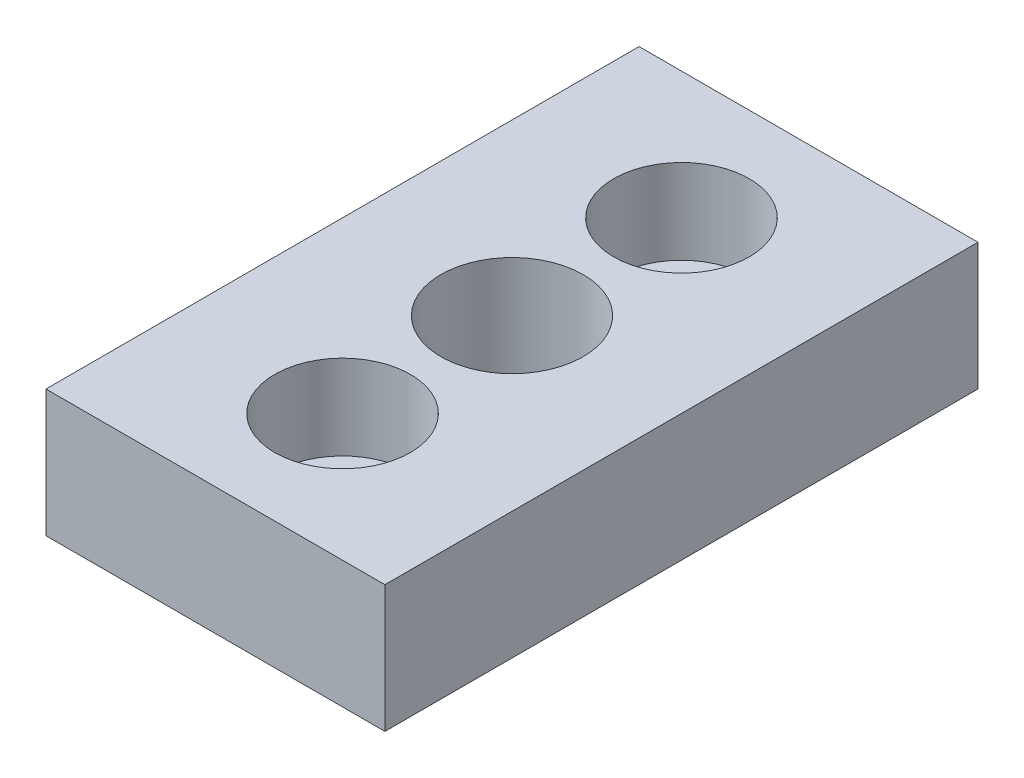
from build123d import *

# Parameters (mm, degrees)
SKETCH1_W           = 20
SKETCH1_H           = 35
BOSS_EXTRUDE1_DEPTH = 7.5
SKETCH3_R           = 4.2
CUT_EXTRUDE1_DEPTH  = 8.5
SKETCH5_R           = 2.5
CUT_EXTRUDE2_DEPTH  = 8.5
SKETCH6_R           = 4
CUT_EXTRUDE3_DEPTH  = 5


with BuildPart() as part:
    # Sketch1 → Boss-Extrude1 (new body)
    with BuildSketch(Plane(origin=(0, 0, 0), x_dir=(1, 0, 0), z_dir=(0, 1, 0))):
        Rectangle(SKETCH1_W, SKETCH1_H)
    extrude(amount=BOSS_EXTRUDE1_DEPTH)

    # Sketch3 → Cut-Extrude1 (cut, through all)
    with BuildSketch(Plane.XZ):
        Circle(SKETCH3_R)
    extrude(amount=-CUT_EXTRUDE1_DEPTH, mode=Mode.SUBTRACT)

    # Sketch5 → Cut-Extrude2 (cut, through all)
    with BuildSketch(Plane.XZ):
        with Locations((0, 10)):
            Circle(SKETCH5_R)
        with Locations((0, -10)):
            Circle(SKETCH5_R)
    extrude(amount=-CUT_EXTRUDE2_DEPTH, mode=Mode.SUBTRACT)

    # Sketch6 → Cut-Extrude3 (cut)
    with BuildSketch(Plane(origin=(0, 7.5, 0), x_dir=(1, 0, 0), z_dir=(0, 1, 0))):
        with Locations((0, 10)):
            Circle(SKETCH6_R)
        with Locations((0, -10)):
            Circle(SKETCH6_R)
    extrude(amount=-CUT_EXTRUDE3_DEPTH, mode=Mode.SUBTRACT)


solid = part.part
